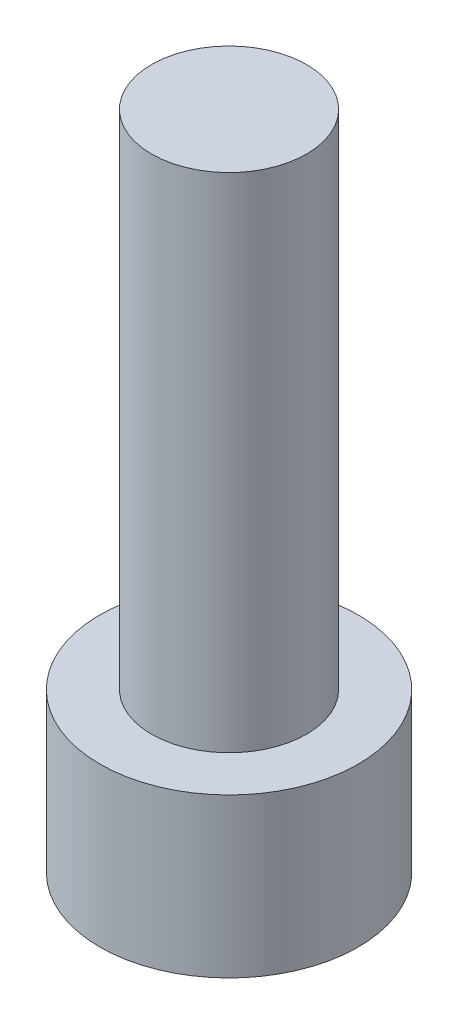
from build123d import *

# Parameters (mm, degrees)
SKETCH1_R           = 2.8575
BOSS_EXTRUDE1_DEPTH = 3.5052
CUT_EXTRUDE1_DEPTH  = 1.9558
SKETCH3_R           = 1.7145
BOSS_EXTRUDE2_DEPTH = 11.1125


with BuildPart() as part:
    # Sketch1 → Boss-Extrude1 (new body)
    with BuildSketch(Plane(origin=(0, 0, 0), x_dir=(1, 0, 0), z_dir=(0, 1, 0))):
        Circle(SKETCH1_R)
    extrude(amount=BOSS_EXTRUDE1_DEPTH)

    # Sketch2 → Cut-Extrude1 (cut)
    with BuildSketch(Plane.XZ):
        Polygon((1.603951217, 0), (0.801975608, 1.3890625), (-0.801975608, 1.3890625), (-1.603951217, 0), (-0.801975608, -1.3890625), (0.801975608, -1.3890625), align=None)
    extrude(amount=-CUT_EXTRUDE1_DEPTH, mode=Mode.SUBTRACT)

    # Sketch3 → Boss-Extrude2 (add)
    with BuildSketch(Plane(origin=(0, 3.5052, 0), x_dir=(1, 0, 0), z_dir=(0, 1, 0))):
        Circle(SKETCH3_R)
    extrude(amount=BOSS_EXTRUDE2_DEPTH)


solid = part.part
